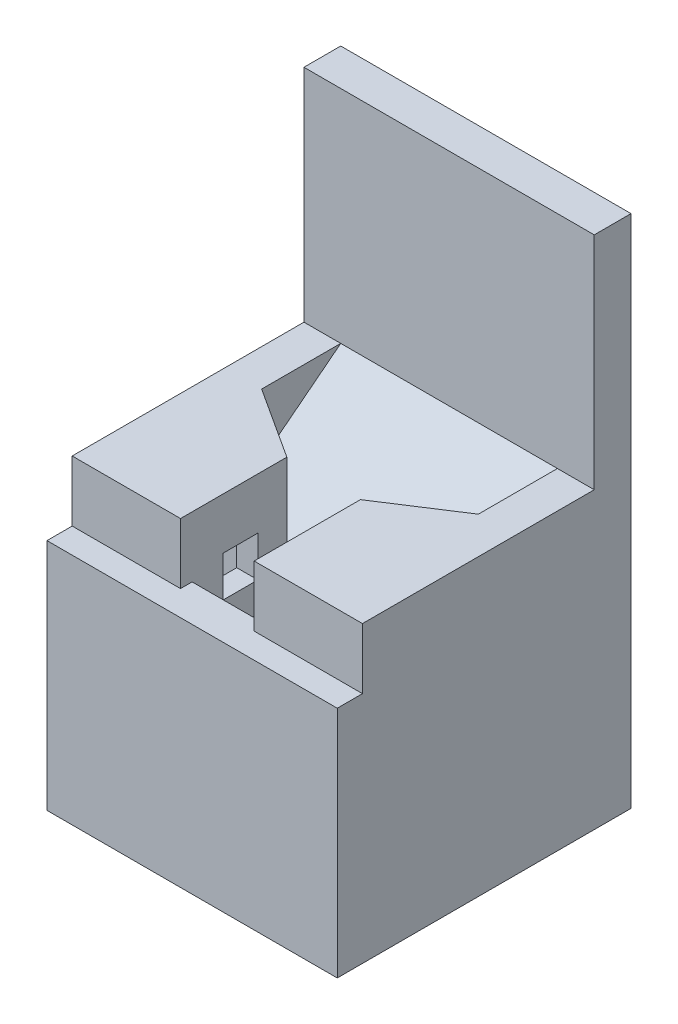
from build123d import *

# Parameters (mm, degrees)
SKETCH2_W            = 18.7
SKETCH2_H            = 20
BOSS_EXTRUDE1_DEPTH  = 25.4
SKETCH3_W            = 6.35
SKETCH3_H            = 3.175
SKETCH3_H_2          = 4.125
CUT_EXTRUDE1_DEPTH   = 34.653863077
SKETCH5_W            = 3.175
SKETCH5_H            = 25.4
BOSS_EXTRUDE2_DEPTH  = 20
SKETCH6_W            = 10
SKETCH6_H            = 10.125
CUT_EXTRUDE2_DEPTH   = 16.825
CUT_EXTRUDE3_REACH   = 34.439
SKETCH7_W            = 3
SKETCH7_H            = 3.5
SKETCH8_W            = 22
SKETCH8_H            = 10.125
CUT_EXTRUDE4_DEPTH   = 19
BOSS_EXTRUDE3_REACH  = 39.049
SKETCH10_W           = 3.175
SKETCH10_H           = 20.1625
BOSS_EXTRUDE10_REACH = 39.695
CUT_EXTRUDE5_REACH   = 33.235
SKETCH12_W           = 6.175
SKETCH12_H           = 10.825
BOSS_EXTRUDE11_REACH = 33.235


with BuildPart() as part:
    # Sketch2 → Boss-Extrude1 (new body)
    with BuildSketch(Plane(origin=(0, 0, 0), x_dir=(1, 0, 0), z_dir=(0, 1, 0))):
        Rectangle(SKETCH2_W, SKETCH2_H)
    extrude(amount=BOSS_EXTRUDE1_DEPTH)

    # Sketch3 → Cut-Extrude1 (cut, through all)
    with BuildSketch(Plane(origin=(0, 0, -10), x_dir=(-1, 0, 0), z_dir=(0, 0, -1))):
        with Locations((0, 16.5125)):
            Rectangle(SKETCH3_W, SKETCH3_H)
        with Locations((0, 20.1625)):
            Rectangle(SKETCH3_W, SKETCH3_H_2)
        with Locations((0, 23.8125)):
            Rectangle(SKETCH3_W, SKETCH3_H)
    extrude(amount=-CUT_EXTRUDE1_DEPTH, mode=Mode.SUBTRACT)

    # Sketch5 → Boss-Extrude2 (add)
    with BuildSketch(Plane(origin=(0, 0, -10), x_dir=(-1, 0, 0), z_dir=(0, 0, -1))):
        with Locations((-10.9375, 12.7)):
            Rectangle(SKETCH5_W, SKETCH5_H)
        with Locations((10.9375, 12.7)):
            Rectangle(SKETCH5_W, SKETCH5_H)
    extrude(amount=-BOSS_EXTRUDE2_DEPTH)

    # Sketch6 → Cut-Extrude2 (cut)
    with BuildSketch(Plane(origin=(0, 0, -10), x_dir=(-1, 0, 0), z_dir=(0, 0, -1))):
        Polygon((5, 22.225), (5, 10.125), (5, 0), (9.35, 0), (9.35, 22.225), align=None)
        with Locations((0, 5.0625)):
            Rectangle(SKETCH6_W, SKETCH6_H)
        Polygon((-5, 22.225), (-9.35, 22.225), (-9.35, 0), (-5, 0), (-5, 10.125), align=None)
    extrude(amount=-CUT_EXTRUDE2_DEPTH, mode=Mode.SUBTRACT)

    # Cut-Extrude3: up to this face of the body (flat: up to its plane)
    cut_extrude3_end = Plane(part.part.faces().sort_by_distance((-5, 16.175, -1.5875))[0])
    # Sketch7 → Cut-Extrude3 (cut, up to the picked face)
    with BuildSketch(Plane(origin=(5, 0, 0), x_dir=(0, 0, -1), z_dir=(1, 0, 0)), mode=Mode.PRIVATE) as cut_extrude3_sk1:
        with Locations((-4.825, 19.225)):
            Rectangle(SKETCH7_W, SKETCH7_H)
    cut_extrude3_tool1 = split(extrude(cut_extrude3_sk1.sketch, amount=-CUT_EXTRUDE3_REACH, mode=Mode.PRIVATE), bisect_by=cut_extrude3_end, keep=Keep.BOTH, mode=Mode.PRIVATE)
    add(cut_extrude3_tool1.solids().sort_by(Axis((5, 19.225, 4.825), (-1, 0, 0)))[0], mode=Mode.SUBTRACT)

    # Sketch8 → Cut-Extrude4 (cut)
    with BuildSketch(Plane(origin=(0, 0, -10), x_dir=(-1, 0, 0), z_dir=(0, 0, -1))):
        with Locations((0, 5.0625)):
            Rectangle(SKETCH8_W, SKETCH8_H)
    extrude(amount=-CUT_EXTRUDE4_DEPTH, mode=Mode.SUBTRACT)

    # Boss-Extrude3: up to this face of the body (flat: up to its plane)
    boss_extrude3_end = Plane(part.part.faces().sort_by_distance((-12.525, 12.7, 0))[0])
    # Sketch10 → Boss-Extrude3 (add, up to the picked face)
    with BuildSketch(Plane(origin=(12.525, 0, 0), x_dir=(0, 0, -1), z_dir=(1, 0, 0)), mode=Mode.PRIVATE) as boss_extrude3_sk1:
        with Locations((-10.5875, 10.08125)):
            Rectangle(SKETCH10_W, SKETCH10_H)
    boss_extrude3_tool1 = split(extrude(boss_extrude3_sk1.sketch, amount=-BOSS_EXTRUDE3_REACH, mode=Mode.PRIVATE), bisect_by=boss_extrude3_end, keep=Keep.BOTH, mode=Mode.PRIVATE)
    add(boss_extrude3_tool1.solids().sort_by(Axis((12.525, 10.08125, 10.5875), (-1, 0, 0)))[0])

    # Boss-Extrude10: up to this face of the body (flat: up to its plane)
    boss_extrude10_end = Plane(part.part.faces().sort_by_distance((-12.525, 12.491899114, 0.881076306))[0])
    # Sketch11 → Boss-Extrude10 (add, up to the picked face)
    with BuildSketch(Plane(origin=(12.525, 0, 0), x_dir=(0, 0, -1), z_dir=(1, 0, 0)), mode=Mode.PRIVATE) as boss_extrude10_sk1:
        Polygon((-0.825, 16.939816253), (-0.825, 12.910183747), (10, 21.370367494), (10, 25.4), align=None)
    boss_extrude10_tool1 = split(extrude(boss_extrude10_sk1.sketch, amount=-BOSS_EXTRUDE10_REACH, mode=Mode.PRIVATE), bisect_by=boss_extrude10_end, keep=Keep.BOTH, mode=Mode.PRIVATE)
    # Sketch11 → Boss-Extrude10 (add, up to the picked face)
    with BuildSketch(Plane(origin=(12.525, 0, 0), x_dir=(0, 0, -1), z_dir=(1, 0, 0)), mode=Mode.PRIVATE) as boss_extrude10_sk2:
        Polygon((13.175, 0), (10, 0), (10, 25.4), (10, 44.45), (13.175, 44.45), align=None)
    boss_extrude10_tool2 = split(extrude(boss_extrude10_sk2.sketch, amount=-BOSS_EXTRUDE10_REACH, mode=Mode.PRIVATE), bisect_by=boss_extrude10_end, keep=Keep.BOTH, mode=Mode.PRIVATE)
    add(boss_extrude10_tool1.solids().sort_by(Axis((12.525, 19.155092, -4.5875), (-1, 0, 0)))[0])
    add(boss_extrude10_tool2.solids().sort_by(Axis((12.525, 22.225, -11.5875), (-1, 0, 0)))[0])

    # Cut-Extrude5: up to this face of the body (flat: up to its plane)
    cut_extrude5_end = Plane(part.part.faces().sort_by_distance((0, 21.169908126, -4.5875))[0])
    # Sketch12 → Cut-Extrude5 (cut, up to the picked face)
    with BuildSketch(Plane(origin=(0, 25.4, 0), x_dir=(1, 0, 0), z_dir=(0, 1, 0)), mode=Mode.PRIVATE) as cut_extrude5_sk1:
        Polygon((-3.175, 10), (-9.35, 10), (-9.35, 3.175), (-3.175, -0.825), align=None)
    cut_extrude5_tool1 = split(extrude(cut_extrude5_sk1.sketch, amount=-CUT_EXTRUDE5_REACH, mode=Mode.PRIVATE), bisect_by=cut_extrude5_end, keep=Keep.BOTH, mode=Mode.PRIVATE)
    # Sketch12 → Cut-Extrude5 (cut, up to the picked face)
    with BuildSketch(Plane(origin=(0, 25.4, 0), x_dir=(1, 0, 0), z_dir=(0, 1, 0)), mode=Mode.PRIVATE) as cut_extrude5_sk2:
        with Locations((6.2625, 4.5875)):
            Rectangle(SKETCH12_W, SKETCH12_H)
    cut_extrude5_tool2 = split(extrude(cut_extrude5_sk2.sketch, amount=-CUT_EXTRUDE5_REACH, mode=Mode.PRIVATE), bisect_by=cut_extrude5_end, keep=Keep.BOTH, mode=Mode.PRIVATE)
    add(cut_extrude5_tool1.solids().sort_by(Axis((-6.029261, 25.4, -5.511957), (0, -1, 0)))[0], mode=Mode.SUBTRACT)
    add(cut_extrude5_tool2.solids().sort_by(Axis((6.2625, 25.4, -4.5875), (0, -1, 0)))[0], mode=Mode.SUBTRACT)

    # Boss-Extrude11: up to this plane
    boss_extrude11_end = Plane(origin=(-59.127601859, 10.916634462, 8.531799857), z_dir=(0, 0.7879130405339252, 0.6157865219023434))
    # Sketch13 → Boss-Extrude11 (add, up to the surface)
    with BuildSketch(Plane(origin=(0, 25.4, 0), x_dir=(1, 0, 0), z_dir=(0, 1, 0)), mode=Mode.PRIVATE) as boss_extrude11_sk1:
        Polygon((-9.35, 3.175), (-9.35, -0.825), (-3.175, -0.825), align=None)
    boss_extrude11_tool1 = split(extrude(boss_extrude11_sk1.sketch, amount=-BOSS_EXTRUDE11_REACH, mode=Mode.PRIVATE), bisect_by=boss_extrude11_end, keep=Keep.BOTH, mode=Mode.PRIVATE)
    add(boss_extrude11_tool1.solids().sort_by_distance((-7.291667, 25.4, -0.508333))[0])
    # Sketch13 → Boss-Extrude11 (add, up to the surface)
    with BuildSketch(Plane(origin=(0, 25.4, 0), x_dir=(1, 0, 0), z_dir=(0, 1, 0)), mode=Mode.PRIVATE) as boss_extrude11_sk2:
        Polygon((9.35, 3.175), (9.35, -0.825), (3.175, -0.825), align=None)
    boss_extrude11_tool2 = split(extrude(boss_extrude11_sk2.sketch, amount=-BOSS_EXTRUDE11_REACH, mode=Mode.PRIVATE), bisect_by=boss_extrude11_end, keep=Keep.BOTH, mode=Mode.PRIVATE)
    add(boss_extrude11_tool2.solids().sort_by_distance((7.291667, 25.4, -0.508333))[0])


solid = part.part
